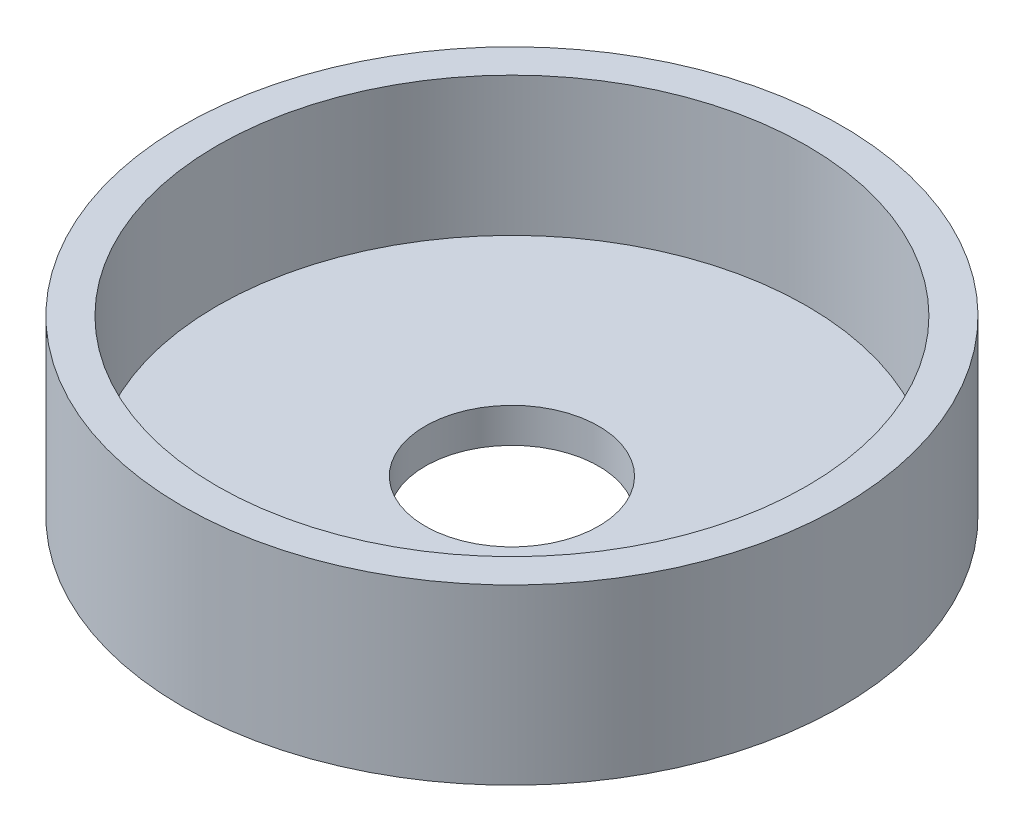
from build123d import *

# Parameters (mm, degrees)
SKETCH1_R           = 9.5
SKETCH1_R_2         = 2.5
BOSS_EXTRUDE1_DEPTH = 1
SKETCH1_3_R         = 9.5
SKETCH1_3_R_2       = 8.5
BOSS_EXTRUDE2_DEPTH = 5


with BuildPart() as part:
    # Sketch1 → Boss-Extrude1 (new body)
    with BuildSketch(Plane(origin=(0, 0, 0), x_dir=(1, 0, 0), z_dir=(0, 1, 0))):
        Circle(SKETCH1_R)
        Circle(SKETCH1_R_2, mode=Mode.SUBTRACT)
    extrude(amount=BOSS_EXTRUDE1_DEPTH)

    # Sketch1_3 → Boss-Extrude2 (add)
    with BuildSketch(Plane(origin=(0, 0, 0), x_dir=(1, 0, 0), z_dir=(0, 1, 0))):
        Circle(SKETCH1_3_R)
        Circle(SKETCH1_3_R_2, mode=Mode.SUBTRACT)
    extrude(amount=BOSS_EXTRUDE2_DEPTH)


solid = part.part
